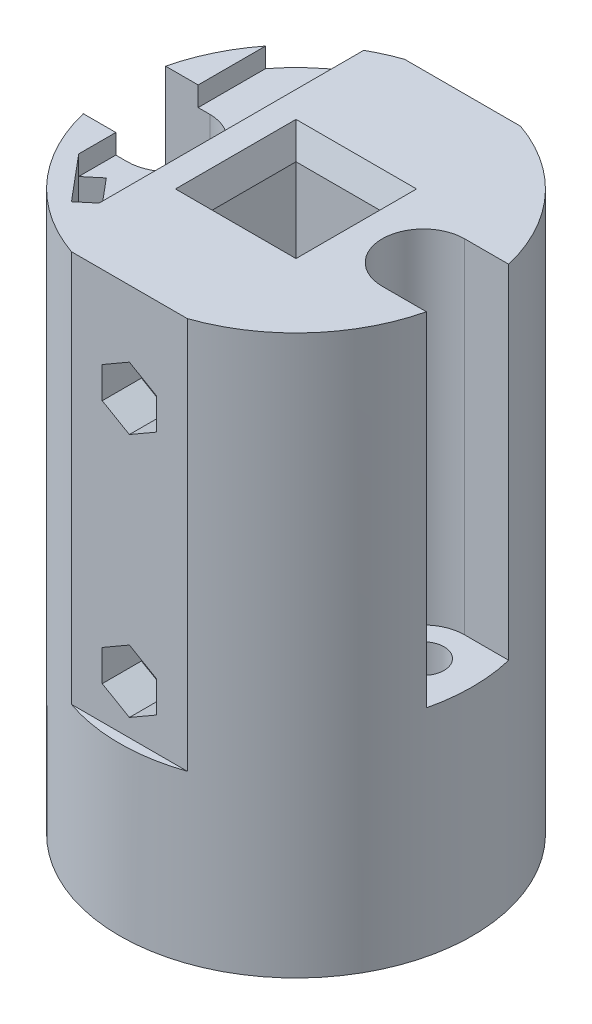
from build123d import *

# Parameters (mm, degrees)
SKETCH1_R           = 18
SKETCH1_R_2         = 2.1
SKETCH1_W           = 10.3
SKETCH1_H           = 10.3
BOSS_EXTRUDE1_DEPTH = 57
CUT_EXTRUDE4_DEPTH  = 40
SKETCH6_R           = 1.5
CUT_EXTRUDE5_DEPTH  = 36
SKETCH7_R           = 3
CUT_EXTRUDE6_DEPTH  = 3
CUT_EXTRUDE7_DEPTH  = 4
CHAMFER1_SIZE       = 1
CHAMFER1_SIZE2      = 2.747477419
CUT_EXTRUDE9_DEPTH  = 6
CHAMFER2_SIZE       = 0.5
CHAMFER2_SIZE2      = 1.37373871
CUT_EXTRUDE10_DEPTH = 35
CUT_EXTRUDE11_DEPTH = 58
CHAMFER3_SIZE       = 0.5
CHAMFER3_SIZE2      = 1.37373871
CUT_EXTRUDE13_DEPTH = 2


with BuildPart() as part:
    # Sketch1 → Boss-Extrude1 (new body)
    with BuildSketch(Plane(origin=(0, 0, 0), x_dir=(1, 0, 0), z_dir=(0, 1, 0))):
        Circle(SKETCH1_R)
        with Locations((13, 0)):
            Circle(SKETCH1_R_2, mode=Mode.SUBTRACT)
        with Locations((-13, 0)):
            Circle(SKETCH1_R_2, mode=Mode.SUBTRACT)
        Rectangle(SKETCH1_W, SKETCH1_H, mode=Mode.SUBTRACT)
    extrude(amount=BOSS_EXTRUDE1_DEPTH)

    # Sketch5 → Cut-Extrude4 (cut)
    with BuildSketch(Plane(origin=(0, 57, 0), x_dir=(1, 0, 0), z_dir=(0, 1, 0))):
        with BuildLine():
            Line((5.916079783, 17), (-5.916079783, 17))
            ThreePointArc((-5.916079783, 17), (0, 18), (5.916079783, 17))
        make_face()
        with BuildLine():
            Line((5.916079783, -17), (-5.916079783, -17))
            ThreePointArc((-5.916079783, -17), (0, -18), (5.916079783, -17))
        make_face()
    extrude(amount=-CUT_EXTRUDE4_DEPTH, mode=Mode.SUBTRACT)

    # Sketch6 → Cut-Extrude5 (cut, through all)
    with BuildSketch(Plane(origin=(0, 0, -17), x_dir=(-1, 0, 0), z_dir=(0, 0, -1))):
        with Locations((0, 47)):
            Circle(SKETCH6_R)
        with Locations((0, 22)):
            Circle(SKETCH6_R)
    extrude(amount=-CUT_EXTRUDE5_DEPTH, mode=Mode.SUBTRACT)

    # Sketch7 → Cut-Extrude6 (cut)
    with BuildSketch(Plane(origin=(0, 0, -17), x_dir=(-1, 0, 0), z_dir=(0, 0, -1))):
        with Locations((0, 47)):
            Circle(SKETCH7_R)
        with Locations((0, 22)):
            Circle(SKETCH7_R)
    extrude(amount=-CUT_EXTRUDE6_DEPTH, mode=Mode.SUBTRACT)

    # Sketch8 → Cut-Extrude7 (cut)
    with BuildSketch(Plane.XY.offset(17)):
        Polygon((0, 43.8), (2.771281292, 45.4), (2.771281292, 48.6), (0, 50.2), (-2.771281292, 48.6), (-2.771281292, 45.4), align=None)
        Polygon((0, 18.8), (2.771281292, 20.4), (2.771281292, 23.6), (0, 25.2), (-2.771281292, 23.6), (-2.771281292, 20.4), align=None)
    extrude(amount=-CUT_EXTRUDE7_DEPTH, mode=Mode.SUBTRACT)

    # Chamfer1
    chamfer1_edges = [part.edges().sort_by_distance(p)[0] for p in [
        (0, 57, -5.15),
        (-5.15, 57, 0),
        (0, 57, 5.15),
        (5.15, 57, 0),
    ]]
    chamfer1_side = [part.faces().sort_by_distance(p)[0] for p in [
        (14.267618119, 57, 10.141691708),
    ]]
    chamfer(chamfer1_edges, length=CHAMFER1_SIZE, length2=CHAMFER1_SIZE2, reference=chamfer1_side[0])

    # Sketch9 → Cut-Extrude9 (cut)
    with BuildSketch(Plane.XZ):
        with BuildLine():
            Line((15.438263477, -3.358179747), (9.406640719, -2.076118753))
            ThreePointArc((9.406640719, -2.076118753), (13.862833517, 4.059312543), (15.438263477, -3.358179747))
        make_face()
        with BuildLine():
            Line((-9.458796565, -2.163880365), (-15.354920877, -3.417140276))
            ThreePointArc((-15.354920877, -3.417140276), (-13.862833517, 4.059312543), (-9.458796565, -2.163880365))
        make_face()
    extrude(amount=-CUT_EXTRUDE9_DEPTH, mode=Mode.SUBTRACT)

    # Chamfer2
    chamfer2_edges = [part.edges().sort_by_distance(p)[0] for p in [
        (13.862833517, 0, 4.059312543),
        (12.422452098, 0, -2.71714925),
        (-13.862833517, 0, 4.059312543),
        (-12.406858721, 0, -2.79051032),
    ]]
    chamfer2_side = [part.faces().sort_by_distance(p)[0] for p in [
        (-17.490883118, 0, 0),
    ]]
    chamfer(chamfer2_edges, length=CHAMFER2_SIZE, length2=CHAMFER2_SIZE2, reference=chamfer2_side[0])

    # Sketch10 → Cut-Extrude10 (cut)
    with BuildSketch(Plane(origin=(0, 57, 0), x_dir=(1, 0, 0), z_dir=(0, 1, 0))):
        with BuildLine():
            Line((13, 4.2), (21, 4.2))
            Line((21, 4.2), (21, -4.2))
            Line((21, -4.2), (13, -4.2))
            ThreePointArc((13, -4.2), (8.8, 0), (13, 4.2))
        make_face()
        with BuildLine():
            Line((-13, 4.2), (-21, 4.2))
            Line((-21, 4.2), (-21, -4.2))
            Line((-21, -4.2), (-13, -4.2))
            ThreePointArc((-13, -4.2), (-8.8, 0), (-13, 4.2))
        make_face()
    extrude(amount=-CUT_EXTRUDE10_DEPTH, mode=Mode.SUBTRACT)

    # Sketch11 → Cut-Extrude11 (cut, through all)
    with BuildSketch(Plane.XZ):
        Polygon((-14.185073919, 7.986468426), (-10.328348261, 12.582735084), (-8.796259375, 11.297159865), (-12.652985033, 6.700893206), align=None)
    extrude(amount=-CUT_EXTRUDE11_DEPTH, mode=Mode.SUBTRACT)

    # Chamfer3
    chamfer3_edges = [part.edges().sort_by_distance(p)[0] for p in [
        (-13.419029476, 0, 7.343680816),
        (-10.724622204, 0, 8.999026536),
        (-9.562303818, 0, 11.939947475),
        (-12.25671109, 0, 10.284601755),
    ]]
    chamfer3_side = [part.faces().sort_by_distance(p)[0] for p in [
        (-17.949088312, 0, 0),
    ]]
    chamfer(chamfer3_edges, length=CHAMFER3_SIZE, length2=CHAMFER3_SIZE2, reference=chamfer3_side[0])

    # Sketch13 → Cut-Extrude13 (cut)
    with BuildSketch(Plane(origin=(0, 57, 0), x_dir=(1, 0, 0), z_dir=(0, 1, 0))):
        with BuildLine():
            Line((-8.796259375, -11.297159865), (-8.796259375, 15.704324914))
            ThreePointArc((-8.796259375, 15.704324914), (-11.720909208, 13.660903606), (-14.185073919, 11.080779662))
            Line((-14.185073919, 11.080779662), (-14.185073919, -7.986468426))
            Line((-14.185073919, -7.986468426), (-8.796259375, -11.297159865))
        make_face()
    extrude(amount=-CUT_EXTRUDE13_DEPTH, mode=Mode.SUBTRACT)


solid = part.part
